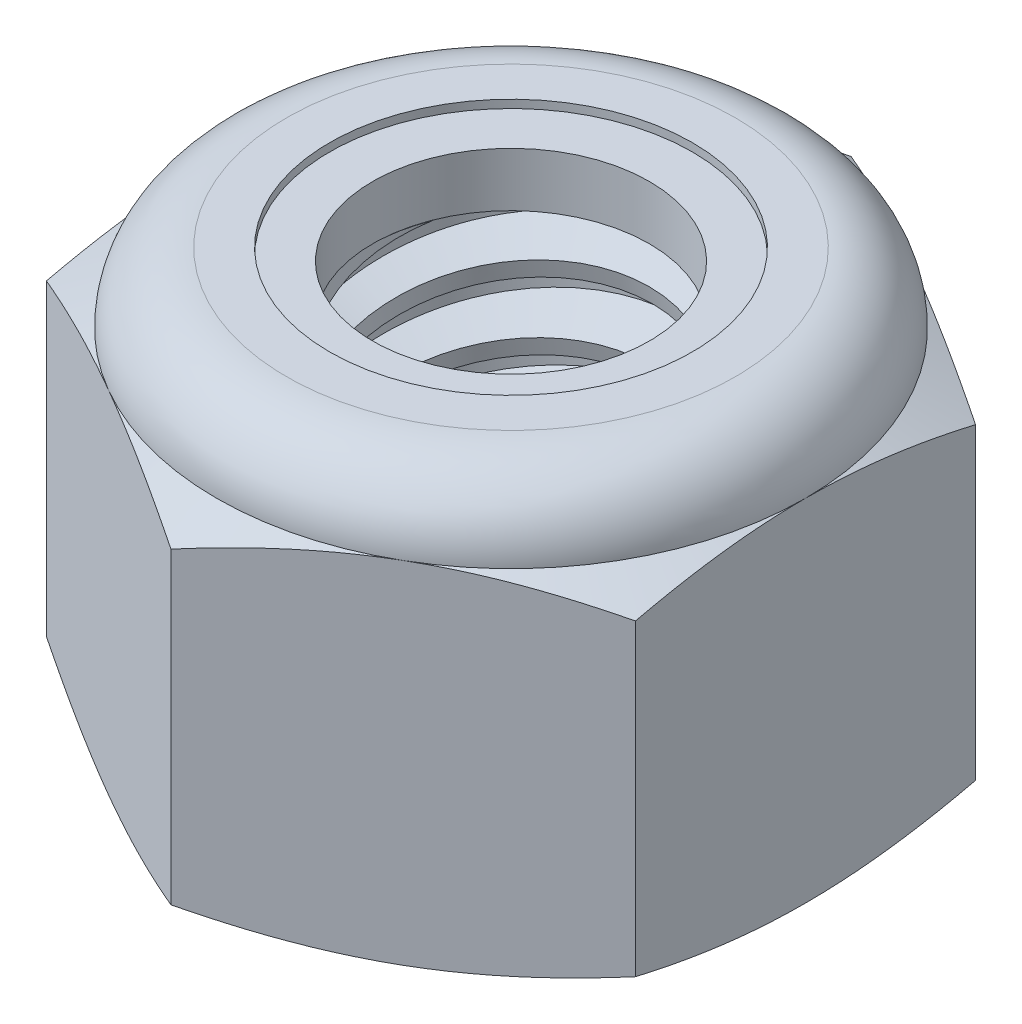
from build123d import *

# Parameters (mm, degrees)
EXTRUDE1_DEPTH      = 7.9375
SKETCH2_W           = 3.175
SKETCH2_H           = 7.9375
LPATTERN1_COUNT     = 6
LPATTERN1_PITCH     = 1.27
LPATTERN1_COL_COUNT = 2
LPATTERN1_COL_PITCH = 1.27


with BuildPart() as part:
    # Sketch1 → Extrude1 (new body)
    with BuildSketch(Plane(origin=(0, 0, 0), x_dir=(1, 0, 0), z_dir=(0, 1, 0))):
        Polygon((0, 6.415804866), (-5.55625, 3.207902433), (-5.55625, -3.207902433), (0, -6.415804866), (5.55625, -3.207902433), (5.55625, 3.207902433), align=None)
    extrude(amount=EXTRUDE1_DEPTH)

    # Sketch4 → Cut-Revolve2 (revolve, cut)
    with BuildSketch(Plane(origin=(0, 0, 0), x_dir=(0, 0, -1), z_dir=(1, 0, 0)), mode=Mode.PRIVATE) as cut_revolve2_sk:
        Polygon((0, 7.9375), (3.175, 7.9375), (2.609908356, 7.673993439), (2.609908356, 0.263506561), (3.175, 0), (0, 0), align=None)
    revolve(cut_revolve2_sk.sketch.rotate(Axis((0, 7.9375, 0), (0, 1, 0)), 54.49881281), axis=Axis((0, 7.9375, 0), (0, 1, 0)), mode=Mode.SUBTRACT)  # turned: the seam where the file's is


with BuildPart() as body_2:
    # Sketch2 → Revolve1 (revolve)
    with BuildSketch(Plane(origin=(0, 0, 0), x_dir=(0, 0, -1), z_dir=(1, 0, 0))):
        with Locations((1.5875, 3.96875)):
            Rectangle(SKETCH2_W, SKETCH2_H)
    revolve(axis=Axis((0, -3.175, 0), (0, 1, 0)))

    # Sketch3 → Cut-Revolve1 (revolve, cut)
    with BuildSketch(Plane(origin=(0, 0, 0), x_dir=(0, 0, -1), z_dir=(1, 0, 0)), mode=Mode.PRIVATE) as cut_revolve1_sk:
        Polygon((3.206133436, 7.781832818), (3.424067492, 6.692162542), (2.672175229, 6.946518763), (2.609908356, 7.257853128), align=None)
    cut_revolve1 = revolve(cut_revolve1_sk.sketch.rotate(Axis((0, 7.9375, 0.272704483), (0, -0.980580676, -0.196116135)), 180), axis=Axis((0, 7.9375, 0.272704483), (0, -0.980580676, -0.196116135)), mode=Mode.SUBTRACT)  # turned: the seam where the file's is

    # LPattern1: Cut-Revolve1 ×6
    with Locations(*[(0, -i * LPATTERN1_PITCH, 0) for i in range(1, LPATTERN1_COUNT)]):
        add(cut_revolve1, mode=Mode.SUBTRACT)

    # LPattern1 col: Cut-Revolve1 ×2
    with Locations(*[(0, i * LPATTERN1_COL_PITCH, 0) for i in range(1, LPATTERN1_COL_COUNT)]):
        add(cut_revolve1, mode=Mode.SUBTRACT)


with BuildPart() as part_1:
    add(part.part)

    # Combine1: cut body 2
    add(body_2.part, mode=Mode.SUBTRACT)

    # Sketch5 → Cut-Revolve3 (revolve, cut)
    with BuildSketch(Plane(origin=(0, 0, 0), x_dir=(0, 0, -1), z_dir=(1, 0, 0)), mode=Mode.PRIVATE) as cut_revolve3_sk:
        with BuildLine():
            Line((0, 0), (5.55625, 0))
            Line((5.55625, 0), (6.415804866, 0.400817017))
            Line((6.415804866, 0.400817017), (6.415804866, 6.213766317))
            Line((6.415804866, 6.213766317), (5.55625, 6.614583333))
            ThreePointArc((5.55625, 6.614583333), (5.168776679, 7.550026679), (4.233333333, 7.9375))
            Line((4.233333333, 7.9375), (4.233333333, 9.2075))
            Line((4.233333333, 9.2075), (7.685804866, 9.2075))
            Line((7.685804866, 9.2075), (7.685804866, -1.27))
            Line((7.685804866, -1.27), (0, -1.27))
            Line((0, -1.27), (0, 0))
        make_face()
    revolve(cut_revolve3_sk.sketch.rotate(Axis((0, 0, 0), (0, 1, 0)), 54.619043446), axis=Axis((0, 0, 0), (0, 1, 0)), mode=Mode.SUBTRACT)  # turned: the seam where the file's is

    # Sketch6 → Cut-Revolve4 (revolve, cut)
    with BuildSketch(Plane(origin=(0, 0, 0), x_dir=(0, 0, -1), z_dir=(1, 0, 0)), mode=Mode.PRIVATE) as cut_revolve4_sk:
        with BuildLine():
            Line((0, 6.614583333), (5.40385, 6.614583333))
            ThreePointArc((5.40385, 6.614583333), (5.061013606, 7.442263606), (4.233333333, 7.7851))
            Line((4.233333333, 7.7851), (3.421620845, 7.7851))
            Line((3.421620845, 7.7851), (3.421620845, 9.2075))
            Line((3.421620845, 9.2075), (0, 9.2075))
            Line((0, 9.2075), (0, 6.614583333))
        make_face()
    revolve(cut_revolve4_sk.sketch.rotate(Axis((0, 9.2075, 0), (0, 1, 0)), 54.49881281), axis=Axis((0, 9.2075, 0), (0, 1, 0)), mode=Mode.SUBTRACT)  # turned: the seam where the file's is


with BuildPart() as body_2_2:
    # Sketch7 → Revolve2 (revolve)
    with BuildSketch(Plane(origin=(0, 0, 0), x_dir=(0, 0, -1), z_dir=(1, 0, 0))):
        with BuildLine():
            Line((2.609908356, 6.690783333), (5.324993778, 6.690783333))
            ThreePointArc((5.324993778, 6.690783333), (4.979705237, 7.4148695), (4.233333333, 7.7089))
            Line((4.233333333, 7.7089), (2.609908356, 7.7089))
            Line((2.609908356, 7.7089), (2.609908356, 6.690783333))
        make_face()
    revolve(axis=Axis((0, 6.690783333, 0), (0, 1, 0)))


solid = Compound([part_1.part, body_2_2.part])
